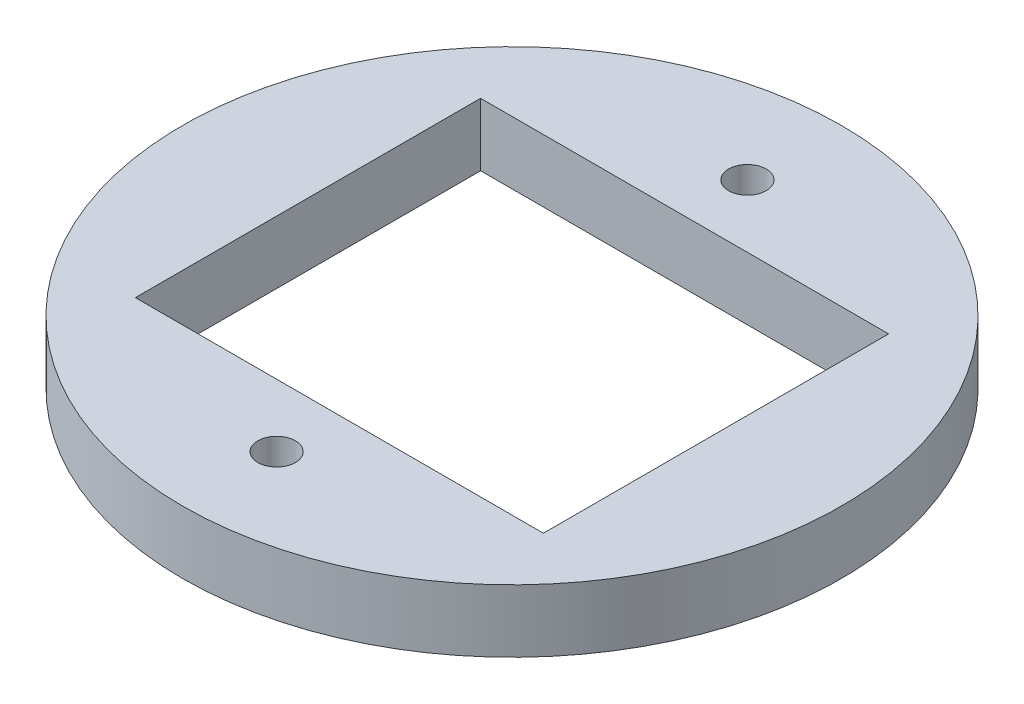
from build123d import *

# Parameters (mm, degrees)
SKETCH1_R           = 26.67
SKETCH1_R_2         = 1.524
BOSS_EXTRUDE2_DEPTH = 5.08
SKETCH4_W           = 33.02
SKETCH4_H           = 27.94
CUT_EXTRUDE1_DEPTH  = 6.08


with BuildPart() as part:
    # Sketch1 → Boss-Extrude2 (new body)
    with BuildSketch(Plane(origin=(0, 0, 0), x_dir=(1, 0, 0), z_dir=(0, 1, 0))):
        Circle(SKETCH1_R)
        with Locations((0, -19.05)):
            Circle(SKETCH1_R_2, mode=Mode.SUBTRACT)
        with Locations((0, 19.05)):
            Circle(SKETCH1_R_2, mode=Mode.SUBTRACT)
    extrude(amount=BOSS_EXTRUDE2_DEPTH)

    # Sketch4 → Cut-Extrude1 (cut, through all)
    with BuildSketch(Plane(origin=(0, 5.08, 0), x_dir=(1, 0, 0), z_dir=(0, 1, 0))):
        Rectangle(SKETCH4_W, SKETCH4_H)
    extrude(amount=-CUT_EXTRUDE1_DEPTH, mode=Mode.SUBTRACT)


solid = part.part
